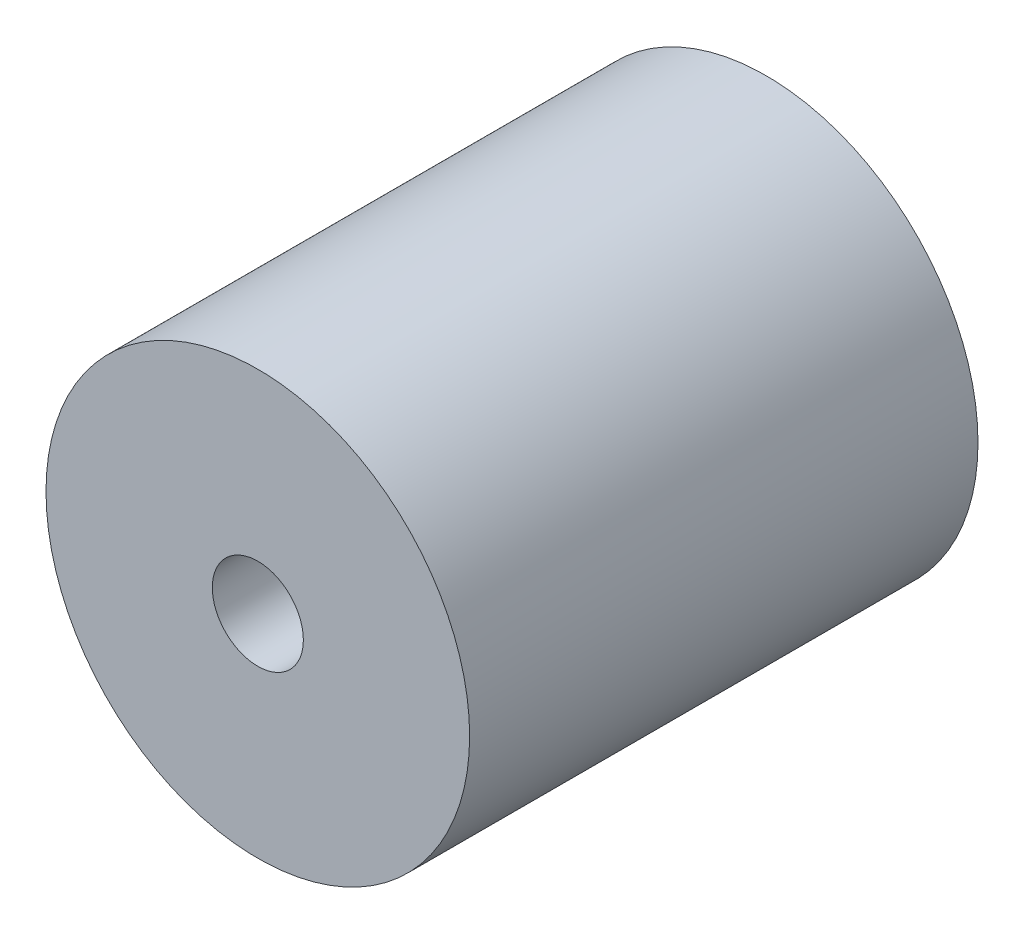
from build123d import *

# Parameters (mm, degrees)
SKETCH1_R           = 10
SKETCH1_R_2         = 2.15
BOSS_EXTRUDE1_DEPTH = 24


with BuildPart() as part:
    # Sketch1 → Boss-Extrude1 (new body)
    with BuildSketch(Plane.XY):
        Circle(SKETCH1_R)
        Circle(SKETCH1_R_2, mode=Mode.SUBTRACT)
    extrude(amount=BOSS_EXTRUDE1_DEPTH)


solid = part.part
